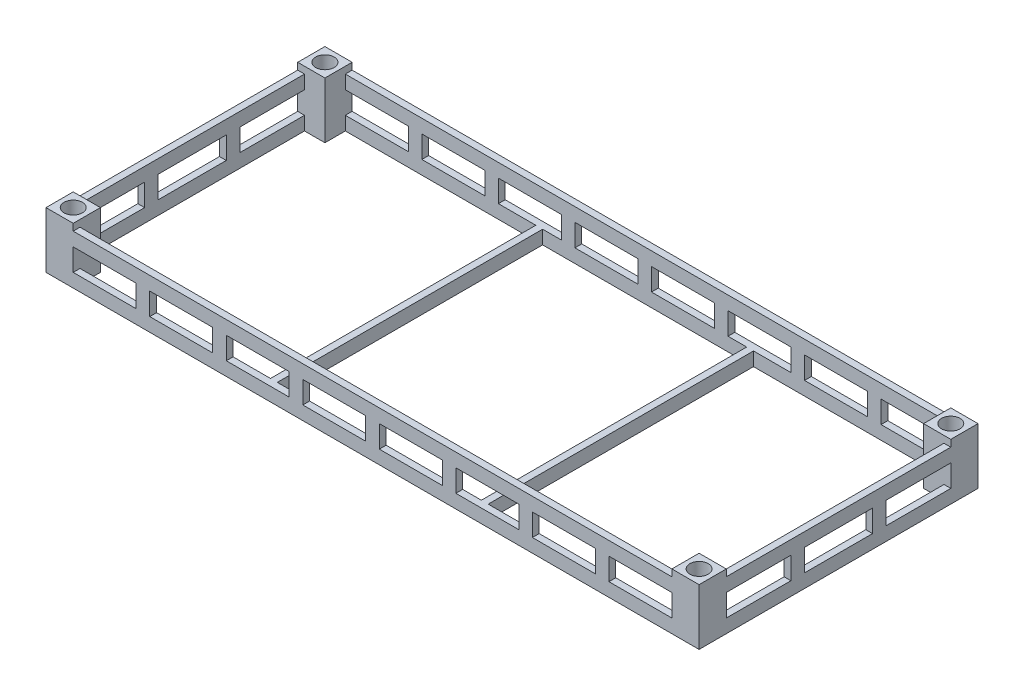
from build123d import *

# Parameters (mm, degrees)
SKETCH1_W               = 900
SKETCH1_H               = 20
SKETCH1_W_2             = 20
SKETCH1_H_2             = 350
SKETCH1_H_3             = 700
BOSS_EXTRUDE1_DEPTH     = 165
SKETCH2_W               = 205
SKETCH2_H               = 65
SKETCH2_W_2             = 185
SKETCH2_W_3             = 1800
SKETCH2_H_2             = 20
CUT_EXTRUDE1_DEPTH      = 1
CUT_EXTRUDE1_DEPTH_BACK = 821
SKETCH3_W               = 200
SKETCH3_H               = 65
SKETCH3_W_2             = 210
CUT_EXTRUDE2_DEPTH      = 1
CUT_EXTRUDE2_DEPTH_BACK = 1921
SKETCH5_W               = 20
SKETCH5_H               = 780
BOSS_EXTRUDE3_DEPTH     = 40
SCALE2_SCALE            = 0.1
SKETCH6_W               = 7
SKETCH6_H               = 7
BOSS_EXTRUDE4_DEPTH     = 16.5
SKETCH7_R               = 2.75
CUT_EXTRUDE3_DEPTH      = 1
CUT_EXTRUDE3_DEPTH_BACK = 17.5
SKETCH8_W               = 8
SKETCH8_H               = 8
BOSS_EXTRUDE5_DEPTH     = 16.5
SKETCH9_R               = 2.7
CUT_EXTRUDE4_DEPTH      = 16.5


with BuildPart() as part:
    # Sketch1 → Boss-Extrude1 (new body)
    with BuildSketch(Plane(origin=(0, 0, 0), x_dir=(1, 0, 0), z_dir=(0, 1, 0))):
        Polygon((5, 815), (0, 815), (0, 765), (5, 765), (5, 790), align=None)
        with BuildLine():
            Line((5, 790), (5, 765))
            Line((5, 765), (12.32233047, 772.32233047))
            ThreePointArc((12.32233047, 772.32233047), (6.903011687, 780.432914191), (5, 790))
        make_face()
        with BuildLine():
            Line((12.32233047, 772.32233047), (5, 765))
            Line((5, 765), (30, 765))
            ThreePointArc((30, 765), (20.432914191, 766.903011687), (12.32233047, 772.32233047))
        make_face()
        Polygon((5, 765), (0, 765), (0, 760), align=None)
        Polygon((5, 765), (0, 760), (20, 760), (60, 760), (60, 765), (55, 765), (30, 765), align=None)
        with BuildLine():
            Line((55, 765), (55, 790))
            ThreePointArc((55, 790), (47.67766953, 772.32233047), (30, 765))
            Line((30, 765), (55, 765))
        make_face()
        Polygon((60, 800), (60, 820), (55, 815), (55, 790), (55, 765), (60, 765), align=None)
        with BuildLine():
            Line((30, 815), (5, 815))
            Line((5, 815), (5, 790))
            ThreePointArc((5, 790), (12.32233047, 807.67766953), (30, 815))
        make_face()
        Polygon((55, 820), (0, 820), (0, 815), (5, 815), (30, 815), (55, 815), align=None)
        with BuildLine():
            Line((47.67766953, 807.67766953), (55, 815))
            Line((55, 815), (30, 815))
            ThreePointArc((30, 815), (39.567085809, 813.096988313), (47.67766953, 807.67766953))
        make_face()
        with BuildLine():
            Line((55, 790), (55, 815))
            Line((55, 815), (47.67766953, 807.67766953))
            ThreePointArc((47.67766953, 807.67766953), (53.096988313, 799.567085809), (55, 790))
        make_face()
        Polygon((60, 820), (55, 820), (55, 815), align=None)
        with Locations((510, 810)):
            Rectangle(SKETCH1_W, SKETCH1_H)
        with Locations((10, 585)):
            Rectangle(SKETCH1_W_2, SKETCH1_H_2)
        with Locations((10, 235)):
            Rectangle(SKETCH1_W_2, SKETCH1_H_2)
        Polygon((5, 55), (0, 60), (0, 55), align=None)
        Polygon((5, 55), (0, 55), (0, 5), (5, 5), (5, 30), align=None)
        Polygon((20, 60), (0, 60), (5, 55), (30, 55), (55, 55), (60, 55), (60, 60), align=None)
        with BuildLine():
            Line((30, 55), (5, 55))
            Line((5, 55), (12.32233047, 47.67766953))
            ThreePointArc((12.32233047, 47.67766953), (20.432914191, 53.096988313), (30, 55))
        make_face()
        with BuildLine():
            Line((12.32233047, 47.67766953), (5, 55))
            Line((5, 55), (5, 30))
            ThreePointArc((5, 30), (6.903011687, 39.567085809), (12.32233047, 47.67766953))
        make_face()
        with BuildLine():
            Line((55, 55), (30, 55))
            ThreePointArc((30, 55), (47.67766953, 47.67766953), (55, 30))
            Line((55, 30), (55, 55))
        make_face()
        Polygon((60, 0), (60, 20), (60, 55), (55, 55), (55, 30), (55, 5), align=None)
        with BuildLine():
            Line((55, 5), (47.67766953, 12.32233047))
            ThreePointArc((47.67766953, 12.32233047), (39.567085809, 6.903011687), (30, 5))
            Line((30, 5), (55, 5))
        make_face()
        with BuildLine():
            ThreePointArc((55, 30), (53.096988313, 20.432914191), (47.67766953, 12.32233047))
            Line((47.67766953, 12.32233047), (55, 5))
            Line((55, 5), (55, 30))
        make_face()
        Polygon((5, 5), (0, 5), (0, 0), (55, 0), (55, 5), (30, 5), align=None)
        Polygon((55, 0), (60, 0), (55, 5), align=None)
        with BuildLine():
            ThreePointArc((30, 5), (12.32233047, 12.32233047), (5, 30))
            Line((5, 30), (5, 5))
            Line((5, 5), (30, 5))
        make_face()
        with Locations((510, 10)):
            Rectangle(SKETCH1_W, SKETCH1_H)
        with Locations((1410, 10)):
            Rectangle(SKETCH1_W, SKETCH1_H)
        Polygon((1860, 55), (1860, 20), (1860, 0), (1865, 5), (1865, 30), (1865, 55), align=None)
        with BuildLine():
            Line((1865, 30), (1865, 5))
            Line((1865, 5), (1872.32233047, 12.32233047))
            ThreePointArc((1872.32233047, 12.32233047), (1866.903011687, 20.432914191), (1865, 30))
        make_face()
        with BuildLine():
            Line((1872.32233047, 12.32233047), (1865, 5))
            Line((1865, 5), (1890, 5))
            ThreePointArc((1890, 5), (1880.432914191, 6.903011687), (1872.32233047, 12.32233047))
        make_face()
        Polygon((1865, 5), (1860, 0), (1865, 0), align=None)
        Polygon((1865, 5), (1865, 0), (1920, 0), (1920, 5), (1915, 5), (1890, 5), align=None)
        with BuildLine():
            ThreePointArc((1915, 30), (1907.67766953, 12.32233047), (1890, 5))
            Line((1890, 5), (1915, 5))
            Line((1915, 5), (1915, 30))
        make_face()
        Polygon((1920, 5), (1920, 55), (1915, 55), (1915, 30), (1915, 5), align=None)
        Polygon((1860, 60), (1860, 55), (1865, 55), (1890, 55), (1915, 55), (1920, 60), (1900, 60), align=None)
        with BuildLine():
            Line((1890, 55), (1865, 55))
            Line((1865, 55), (1865, 30))
            ThreePointArc((1865, 30), (1872.32233047, 47.67766953), (1890, 55))
        make_face()
        with BuildLine():
            Line((1915, 55), (1890, 55))
            ThreePointArc((1890, 55), (1899.567085809, 53.096988313), (1907.67766953, 47.67766953))
            Line((1907.67766953, 47.67766953), (1915, 55))
        make_face()
        Polygon((1920, 55), (1920, 60), (1915, 55), align=None)
        with BuildLine():
            Line((1915, 30), (1915, 55))
            Line((1915, 55), (1907.67766953, 47.67766953))
            ThreePointArc((1907.67766953, 47.67766953), (1913.096988313, 39.567085809), (1915, 30))
        make_face()
        with Locations((1910, 410)):
            Rectangle(SKETCH1_W_2, SKETCH1_H_3)
        Polygon((1865, 765), (1860, 765), (1860, 760), (1900, 760), (1920, 760), (1915, 765), (1890, 765), align=None)
        Polygon((1920, 760), (1920, 765), (1915, 765), align=None)
        with BuildLine():
            ThreePointArc((1915, 790), (1913.096988313, 780.432914191), (1907.67766953, 772.32233047))
            Line((1907.67766953, 772.32233047), (1915, 765))
            Line((1915, 765), (1915, 790))
        make_face()
        with BuildLine():
            Line((1915, 765), (1907.67766953, 772.32233047))
            ThreePointArc((1907.67766953, 772.32233047), (1899.567085809, 766.903011687), (1890, 765))
            Line((1890, 765), (1915, 765))
        make_face()
        Polygon((1920, 765), (1920, 815), (1915, 815), (1915, 790), (1915, 765), align=None)
        Polygon((1920, 820), (1865, 820), (1865, 815), (1890, 815), (1915, 815), (1920, 815), align=None)
        with BuildLine():
            Line((1915, 815), (1890, 815))
            ThreePointArc((1890, 815), (1907.67766953, 807.67766953), (1915, 790))
            Line((1915, 790), (1915, 815))
        make_face()
        Polygon((1865, 820), (1860, 820), (1865, 815), align=None)
        Polygon((1865, 815), (1860, 820), (1860, 800), (1860, 765), (1865, 765), (1865, 790), align=None)
        with BuildLine():
            Line((1872.32233047, 807.67766953), (1865, 815))
            Line((1865, 815), (1865, 790))
            ThreePointArc((1865, 790), (1866.903011687, 799.567085809), (1872.32233047, 807.67766953))
        make_face()
        with BuildLine():
            Line((1890, 815), (1865, 815))
            Line((1865, 815), (1872.32233047, 807.67766953))
            ThreePointArc((1872.32233047, 807.67766953), (1880.432914191, 813.096988313), (1890, 815))
        make_face()
        with BuildLine():
            ThreePointArc((1890, 765), (1872.32233047, 772.32233047), (1865, 790))
            Line((1865, 790), (1865, 765))
            Line((1865, 765), (1890, 765))
        make_face()
        with Locations((1410, 810)):
            Rectangle(SKETCH1_W, SKETCH1_H)
    extrude(amount=BOSS_EXTRUDE1_DEPTH)

    # Sketch2 → Cut-Extrude1 (cut, two sides)
    with BuildSketch(Plane.XY) as cut_extrude1_sk:
        with Locations((162.5, 72.5)):
            Rectangle(SKETCH2_W, SKETCH2_H)
        with Locations((397.5, 72.5)):
            Rectangle(SKETCH2_W_2, SKETCH2_H)
        with Locations((622.5, 72.5)):
            Rectangle(SKETCH2_W_2, SKETCH2_H)
        with Locations((847.5, 72.5)):
            Rectangle(SKETCH2_W_2, SKETCH2_H)
        with Locations((1072.5, 72.5)):
            Rectangle(SKETCH2_W_2, SKETCH2_H)
        with Locations((1297.5, 72.5)):
            Rectangle(SKETCH2_W_2, SKETCH2_H)
        with Locations((1522.5, 72.5)):
            Rectangle(SKETCH2_W_2, SKETCH2_H)
        with Locations((1757.5, 72.5)):
            Rectangle(SKETCH2_W, SKETCH2_H)
        with Locations((960, 155)):
            Rectangle(SKETCH2_W_3, SKETCH2_H_2)
    extrude(amount=CUT_EXTRUDE1_DEPTH, mode=Mode.SUBTRACT)
    extrude(cut_extrude1_sk.sketch, amount=-CUT_EXTRUDE1_DEPTH_BACK, mode=Mode.SUBTRACT)

    # Sketch3 → Cut-Extrude2 (cut, two sides)
    with BuildSketch(Plane(origin=(1920, 0, 0), x_dir=(0, 0, -1), z_dir=(1, 0, 0))) as cut_extrude2_sk:
        Polygon((410, 145), (410, 165), (60, 165), (60, 145), (270, 145), (310, 145), align=None)
        Polygon((760, 145), (760, 165), (410, 165), (410, 145), (510, 145), (550, 145), align=None)
        with Locations((410, 72.5)):
            Rectangle(SKETCH3_W, SKETCH3_H)
        with Locations((655, 72.5)):
            Rectangle(SKETCH3_W_2, SKETCH3_H)
        with Locations((165, 72.5)):
            Rectangle(SKETCH3_W_2, SKETCH3_H)
    extrude(amount=CUT_EXTRUDE2_DEPTH, mode=Mode.SUBTRACT)
    extrude(cut_extrude2_sk.sketch, amount=-CUT_EXTRUDE2_DEPTH_BACK, mode=Mode.SUBTRACT)

    # Sketch5 → Boss-Extrude3 (add)
    with BuildSketch(Plane.XZ):
        with Locations((650, -410)):
            Rectangle(SKETCH5_W, SKETCH5_H)
        with Locations((1270, -410)):
            Rectangle(SKETCH5_W, SKETCH5_H)
    extrude(amount=-BOSS_EXTRUDE3_DEPTH)


with BuildPart() as part_1:
    # Scale2: scaled about (960, 67.642168167, -410)
    add(part.part.scale(SCALE2_SCALE).moved(Location((864, 60.87795135, -369))))

    # Sketch6 → Boss-Extrude4 (add)
    with BuildSketch(Plane(origin=(0, 77.37795135, 0), x_dir=(1, 0, 0), z_dir=(0, 1, 0))):
        with Locations((1052.5, 372.5)):
            Rectangle(SKETCH6_W, SKETCH6_H)
        with Locations((867.5, 372.5)):
            Rectangle(SKETCH6_W, SKETCH6_H)
        with Locations((1052.5, 447.5)):
            Rectangle(SKETCH6_W, SKETCH6_H)
        with Locations((867.5, 447.5)):
            Rectangle(SKETCH6_W, SKETCH6_H)
    extrude(amount=-BOSS_EXTRUDE4_DEPTH)

    # Sketch7 → Cut-Extrude3 (cut, two sides)
    with BuildSketch(Plane(origin=(0, 77.37795135, 0), x_dir=(1, 0, 0), z_dir=(0, 1, 0))) as cut_extrude3_sk:
        with BuildLine():
            ThreePointArc((1052.5, 375.25), (1049.75, 372.5), (1052.5, 369.75))
            Line((1052.5, 369.75), (1052.5, 375.25))
        make_face()
        with BuildLine():
            Line((1052.5, 375.25), (1052.5, 369.75))
            ThreePointArc((1052.5, 369.75), (1054.444543648, 370.555456352), (1055.25, 372.5))
            ThreePointArc((1055.25, 372.5), (1054.444543648, 374.444543648), (1052.5, 375.25))
        make_face()
        with BuildLine():
            ThreePointArc((1055.25, 447.5), (1054.444543648, 449.444543648), (1052.5, 450.25))
            Line((1052.5, 450.25), (1052.5, 444.75))
            ThreePointArc((1052.5, 444.75), (1054.444543648, 445.555456352), (1055.25, 447.5))
        make_face()
        with BuildLine():
            Line((1052.5, 444.75), (1052.5, 450.25))
            ThreePointArc((1052.5, 450.25), (1049.75, 447.5), (1052.5, 444.75))
        make_face()
        with Locations((867.5, 447.5)):
            Circle(SKETCH7_R)
        with Locations((867.5, 372.5)):
            Circle(SKETCH7_R)
    extrude(amount=CUT_EXTRUDE3_DEPTH, mode=Mode.SUBTRACT)
    extrude(cut_extrude3_sk.sketch, amount=-CUT_EXTRUDE3_DEPTH_BACK, mode=Mode.SUBTRACT)

    # Sketch8 → Boss-Extrude5 (add)
    with BuildSketch(Plane(origin=(0, 60.87795135, 0), x_dir=(-1, 0, 0), z_dir=(0, -1, 0))):
        with Locations((-868, 373)):
            Rectangle(SKETCH8_W, SKETCH8_H)
        with Locations((-1052, 447)):
            Rectangle(SKETCH8_W, SKETCH8_H)
        with Locations((-1052, 373)):
            Rectangle(SKETCH8_W, SKETCH8_H)
        with Locations((-868, 447)):
            Rectangle(SKETCH8_W, SKETCH8_H)
    extrude(amount=-BOSS_EXTRUDE5_DEPTH)

    # Sketch9 → Cut-Extrude4 (cut)
    with BuildSketch(Plane(origin=(0, 60.87795135, 0), x_dir=(-1, 0, 0), z_dir=(0, -1, 0))):
        with BuildLine():
            ThreePointArc((-1053.909188309, 448.909188309), (-1053.909188309, 445.090811691), (-1050.090811691, 445.090811691))
            Line((-1050.090811691, 445.090811691), (-1053.909188309, 448.909188309))
        make_face()
        with BuildLine():
            Line((-1053.909188309, 448.909188309), (-1050.090811691, 445.090811691))
            ThreePointArc((-1050.090811691, 445.090811691), (-1049.505525262, 445.966754733), (-1049.3, 447))
            ThreePointArc((-1049.3, 447), (-1050.966754733, 449.494474738), (-1053.909188309, 448.909188309))
        make_face()
        with BuildLine():
            ThreePointArc((-1050.090811691, 374.909188309), (-1053.909188309, 374.909188309), (-1053.909188309, 371.090811691))
            Line((-1053.909188309, 371.090811691), (-1050.090811691, 374.909188309))
        make_face()
        with BuildLine():
            Line((-1050.090811691, 374.909188309), (-1053.909188309, 371.090811691))
            ThreePointArc((-1053.909188309, 371.090811691), (-1050.966754733, 370.505525262), (-1049.3, 373))
            ThreePointArc((-1049.3, 373), (-1049.505525262, 374.033245267), (-1050.090811691, 374.909188309))
        make_face()
        with Locations((-868, 447)):
            Circle(SKETCH9_R)
        with Locations((-868, 373)):
            Circle(SKETCH9_R)
    extrude(amount=-CUT_EXTRUDE4_DEPTH, mode=Mode.SUBTRACT)


solid = part_1.part
